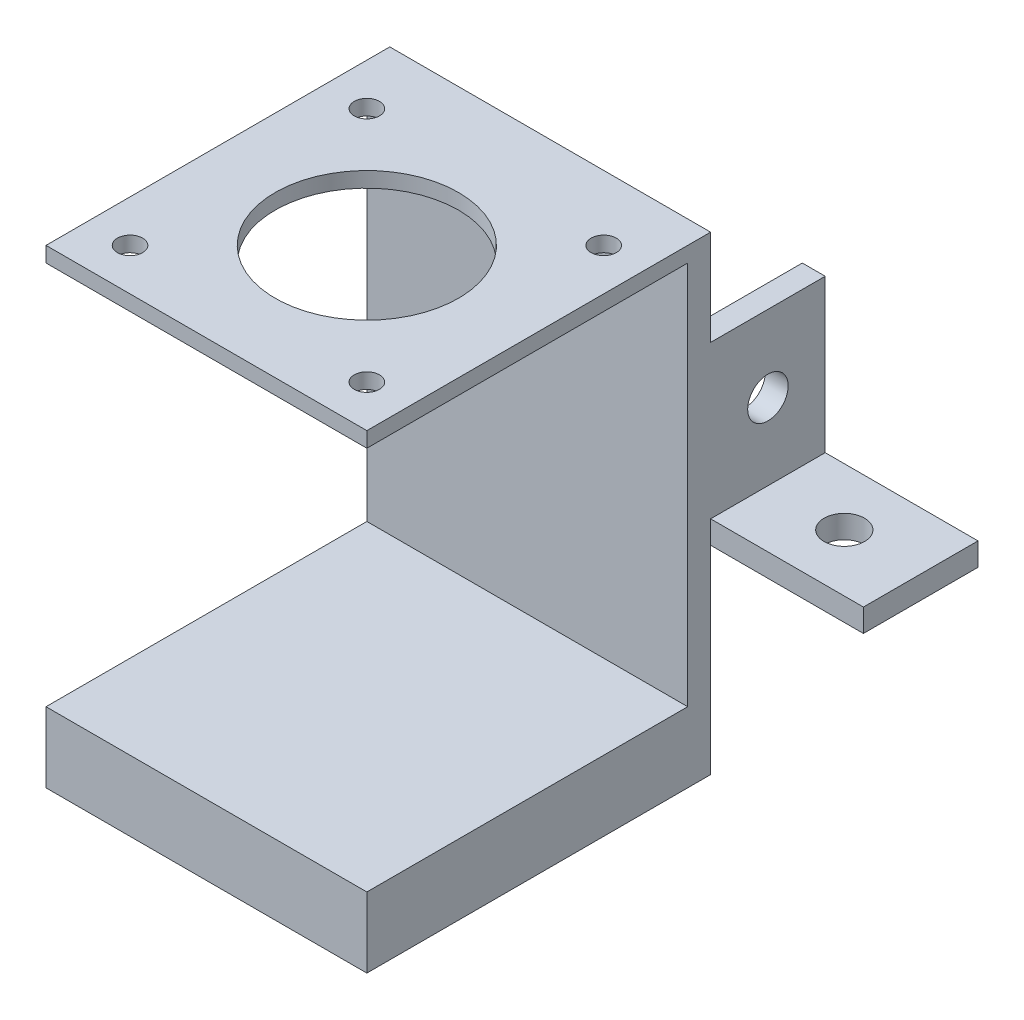
from build123d import *

# Parameters (mm, degrees)
SKETCH_1_W          = 42
SKETCH_1_H          = 61.5
EXTRUDE_1_DEPTH     = 3
SKETCH_2_W          = 42
SKETCH_2_H          = 9.2
SKETCH_2_H_2        = 2
EXTRUDE_2_DEPTH     = 42
SKETCH_3_R          = 12
SKETCH_3_R_2        = 1.65
CUT_EXTRUDE_1_DEPTH = 3
EXTRUDE_3_DEPTH     = 15
SKETCH_6_R          = 2.65
CUT_EXTRUDE_2_DEPTH = 5
SKETCH_7_W          = 15
SKETCH_7_H          = 3
EXTRUDE_4_DEPTH     = 20
SKETCH_8_R          = 2.65
CUT_EXTRUDE_3_DEPTH = 20


with BuildPart() as part:
    # 草图1 → 凸台-拉伸1 (new body)
    with BuildSketch(Plane.XY):
        with Locations((2.806034483, -19.390086207)):
            Rectangle(SKETCH_1_W, SKETCH_1_H)
    extrude(amount=EXTRUDE_1_DEPTH)

    # 草图2 → 凸台-拉伸2 (add)
    with BuildSketch(Plane.XY.offset(3)):
        with Locations((2.806034483, -45.540086207)):
            Rectangle(SKETCH_2_W, SKETCH_2_H)
        with Locations((2.806034483, 10.359913793)):
            Rectangle(SKETCH_2_W, SKETCH_2_H_2)
    extrude(amount=EXTRUDE_2_DEPTH)

    # 草图3 → 切除-拉伸1 (cut, through all)
    with BuildSketch(Plane.XZ.offset(-9.359913793)):
        with Locations((2.806034483, 24)):
            Circle(SKETCH_3_R)
        with Locations((18.306034483, 39.5)):
            Circle(SKETCH_3_R_2)
        with Locations((18.306034483, 8.5)):
            Circle(SKETCH_3_R_2)
        with Locations((-12.693965517, 8.5)):
            Circle(SKETCH_3_R_2)
        with Locations((-12.693965517, 39.5)):
            Circle(SKETCH_3_R_2)
    extrude(amount=-CUT_EXTRUDE_1_DEPTH, mode=Mode.SUBTRACT)

    # 草图4 → 凸台-拉伸3 (add)
    with BuildSketch(Plane(origin=(0, 0, 0), x_dir=(-1, 0, 0), z_dir=(0, 0, -1))):
        Polygon((-23.806034483, -21.140086207), (-23.806034483, -1.140086207), (-20.806034483, -1.140086207), (-20.806034483, -21.140086207), (-20.806034483, -24.140086207), (-23.806034483, -24.140086207), align=None)
    extrude(amount=EXTRUDE_3_DEPTH)

    # 草图6 → 切除-拉伸2 (cut)
    with BuildSketch(Plane.ZY.offset(-20.806034483)):
        with Locations((-7.5, -11.140086207)):
            Circle(SKETCH_6_R)
    extrude(amount=-CUT_EXTRUDE_2_DEPTH, mode=Mode.SUBTRACT)

    # 草图7 → 凸台-拉伸4 (add)
    with BuildSketch(Plane(origin=(23.806034483, 0, 0), x_dir=(0, 0, -1), z_dir=(1, 0, 0))):
        with Locations((7.5, -22.640086207)):
            Rectangle(SKETCH_7_W, SKETCH_7_H)
    extrude(amount=EXTRUDE_4_DEPTH)

    # 草图8 → 切除-拉伸3 (cut)
    with BuildSketch(Plane(origin=(0, -21.140086207, 0), x_dir=(1, 0, 0), z_dir=(0, 1, 0))):
        with Locations((33.806034483, 7.5)):
            Circle(SKETCH_8_R)
    extrude(amount=-CUT_EXTRUDE_3_DEPTH, mode=Mode.SUBTRACT)


solid = part.part
